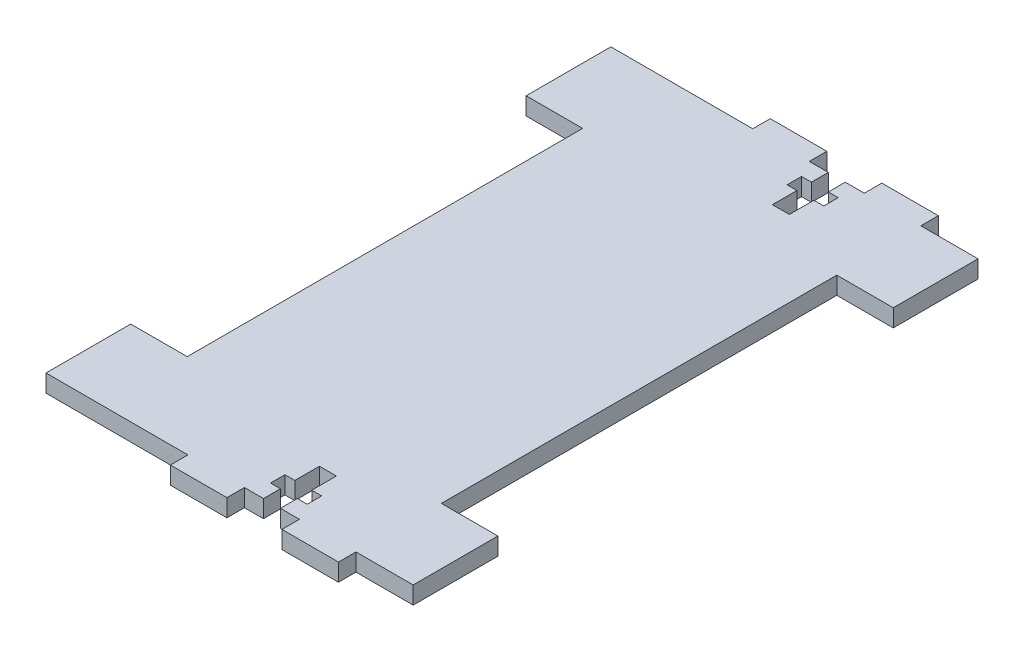
from build123d import *

# Parameters (mm, degrees)
EXTRUDE_1_DEPTH = 3.1


with BuildPart() as part:
    # 草图1 → 凸台-拉伸1 (new body)
    with BuildSketch(Plane(origin=(0, 0, 0), x_dir=(1, 0, 0), z_dir=(0, 1, 0))):
        Polygon((-14.875, 50), (-40, 50), (-40, 35), (-30, 35), (-30, -35), (-40, -35), (-40, -50), (-14.875, -50), (-14.875, -53.1), (-4.875, -53.1), (-4.875, -50), (-1.5, -50), (-1.5, -47), (-3.25, -47), (-3.25, -44.45), (-1.5, -44.45), (-1.5, -40.1), (1.5, -40.1), (1.5, -44.45), (3.25, -44.45), (3.25, -47), (1.5, -47), (1.5, -50), (4.875, -50), (4.875, -53.1), (14.875, -53.1), (14.875, -50), (25, -50), (25, -35), (15, -35), (15, 35), (25, 35), (25, 50), (14.875, 50), (14.875, 53.1), (4.875, 53.1), (4.875, 50), (1.5, 50), (1.5, 47), (3.25, 47), (3.25, 44.45), (1.5, 44.45), (1.5, 40.1), (-1.5, 40.1), (-1.5, 44.45), (-3.25, 44.45), (-3.25, 47), (-1.5, 47), (-1.5, 50), (-4.875, 50), (-4.875, 53.1), (-14.875, 53.1), align=None)
    extrude(amount=EXTRUDE_1_DEPTH)


solid = part.part
